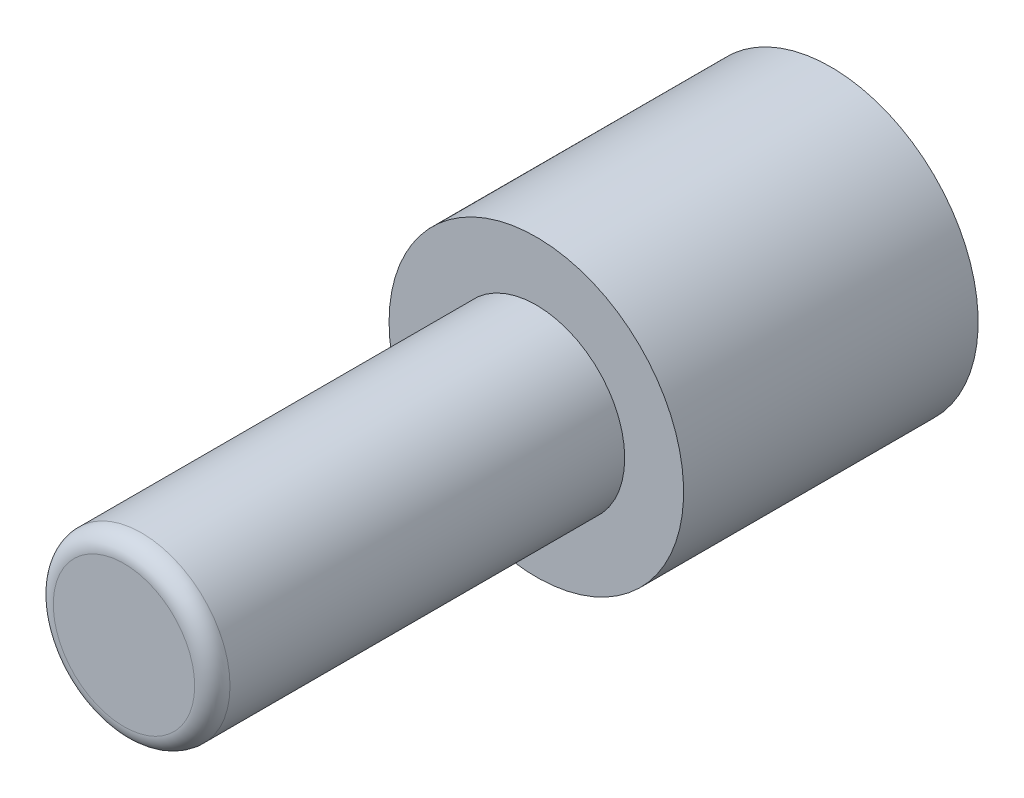
from build123d import *

# Parameters (mm, degrees)
SKETCH1_R           = 1.5
BOSS_EXTRUDE1_DEPTH = 7
SKETCH2_R           = 2.5
BOSS_EXTRUDE2_DEPTH = 5
FILLET2_R           = 0.3


with BuildPart() as part:
    # Sketch1 → Boss-Extrude1 (new body)
    with BuildSketch(Plane.XY):
        Circle(SKETCH1_R)
    extrude(amount=BOSS_EXTRUDE1_DEPTH)

    # Sketch2 → Boss-Extrude2 (add)
    with BuildSketch(Plane(origin=(0, 0, 0), x_dir=(-1, 0, 0), z_dir=(0, 0, -1))):
        Circle(SKETCH2_R)
    extrude(amount=BOSS_EXTRUDE2_DEPTH)

    # Fillet2
    fillet2_edges = [part.edges().sort_by_distance(p)[0] for p in [
        (-1.5, 0, 7),
    ]]
    fillet(fillet2_edges, radius=FILLET2_R)


solid = part.part
